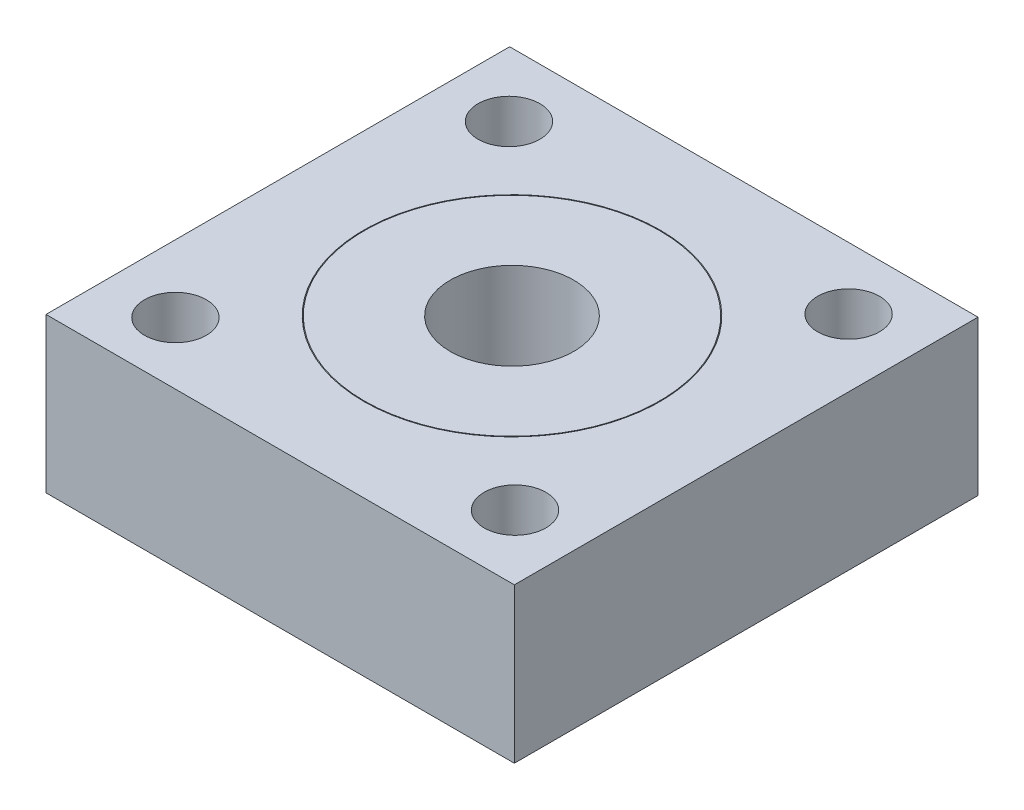
from build123d import *

# Parameters (mm, degrees)
SKETCH1_W           = 30.30738701
SKETCH1_H           = 30.002560534
BOSS_EXTRUDE1_DEPTH = 10
SKETCH2_R           = 9.6
SKETCH2_R_2         = 9.55
CUT_EXTRUDE1_DEPTH  = 7
SKETCH3_R           = 4
CUT_EXTRUDE2_DEPTH  = 10
SKETCH4_R           = 2
CUT_EXTRUDE3_DEPTH  = 10
CIRPATTERN1_COUNT   = 4


with BuildPart() as part:
    # Sketch1 → Boss-Extrude1 (new body)
    with BuildSketch(Plane(origin=(0, 0, 0), x_dir=(1, 0, 0), z_dir=(0, 1, 0))):
        Rectangle(SKETCH1_W, SKETCH1_H)
    extrude(amount=BOSS_EXTRUDE1_DEPTH)

    # Sketch2 → Cut-Extrude1 (cut)
    with BuildSketch(Plane(origin=(0, 10, 0), x_dir=(1, 0, 0), z_dir=(0, 1, 0))):
        Circle(SKETCH2_R)
        Circle(SKETCH2_R_2, mode=Mode.SUBTRACT)
    extrude(amount=-CUT_EXTRUDE1_DEPTH, mode=Mode.SUBTRACT)

    # Sketch3 → Cut-Extrude2 (cut)
    with BuildSketch(Plane(origin=(0, 10, 0), x_dir=(1, 0, 0), z_dir=(0, 1, 0))):
        Circle(SKETCH3_R)
    extrude(amount=-CUT_EXTRUDE2_DEPTH, mode=Mode.SUBTRACT)

    # Sketch4 → Cut-Extrude3 (cut)
    with BuildSketch(Plane(origin=(0, 10, 0), x_dir=(1, 0, 0), z_dir=(0, 1, 0))):
        with Locations((10.792349727, 10.987509758)):
            Circle(SKETCH4_R)
    cut_extrude3 = extrude(amount=-CUT_EXTRUDE3_DEPTH, mode=Mode.SUBTRACT)

    # CirPattern1: Cut-Extrude3 ×4 about axis
    cirpattern1_axis = Axis((0, 0, 0), (0, 1, 0))
    for i in range(1, CIRPATTERN1_COUNT):
        add(cut_extrude3.rotate(cirpattern1_axis, i * 360 / CIRPATTERN1_COUNT), mode=Mode.SUBTRACT)


solid = part.part
